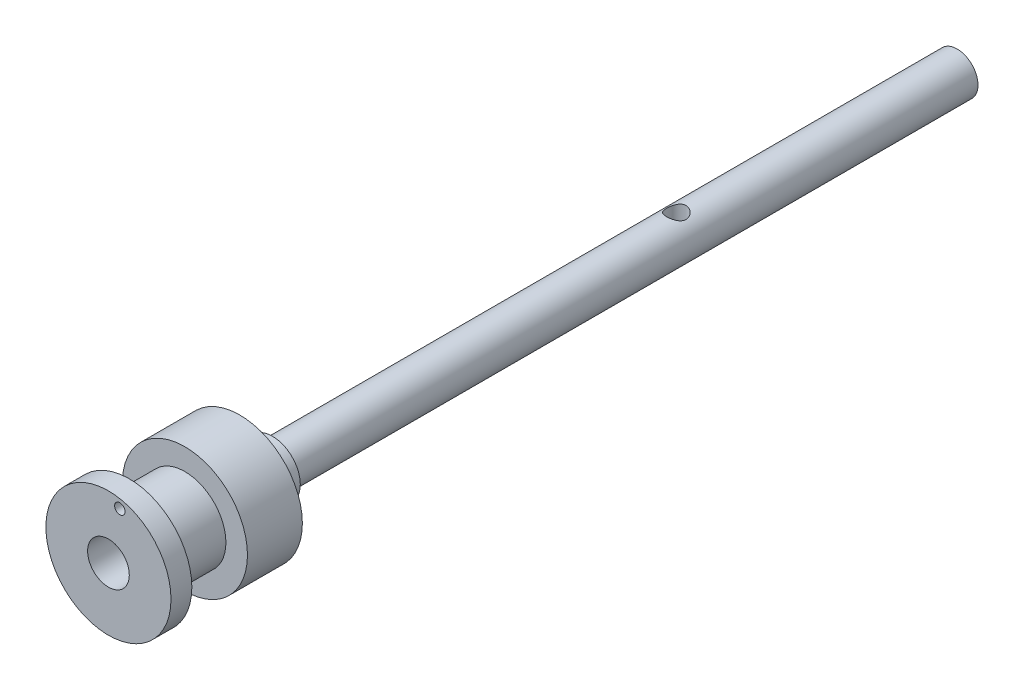
from build123d import *

# Parameters (mm, degrees)
SKETCH1_R               = 3
BOSS_EXTRUDE1_DEPTH     = 98.5
SKETCH2_R               = 4
BOSS_EXTRUDE2_DEPTH     = 4.7
SKETCH3_R               = 9
BOSS_EXTRUDE3_DEPTH     = 7.9
SKETCH4_R               = 5.9
BOSS_EXTRUDE4_DEPTH     = 8
SKETCH5_R               = 9
BOSS_EXTRUDE5_DEPTH     = 3
CUT_EXTRUDE1_DEPTH      = 82
CUT_EXTRUDE1_DEPTH_BACK = 82
SKETCH6_R               = 1.4
CUT_EXTRUDE2_START      = -9
SKETCH7_R               = 3
SKETCH7_R_2             = 0.75
CUT_EXTRUDE2_DEPTH      = 9


with BuildPart() as part:
    # Sketch1 → Boss-Extrude1 (new body)
    with BuildSketch(Plane.XY):
        Circle(SKETCH1_R)
    extrude(amount=BOSS_EXTRUDE1_DEPTH)

    # Sketch2 → Boss-Extrude2 (add)
    with BuildSketch(Plane.XY.offset(98.5)):
        Circle(SKETCH2_R)
    extrude(amount=BOSS_EXTRUDE2_DEPTH)

    # Sketch3 → Boss-Extrude3 (add)
    with BuildSketch(Plane.XY.offset(103.2)):
        Circle(SKETCH3_R)
    extrude(amount=BOSS_EXTRUDE3_DEPTH)

    # Sketch4 → Boss-Extrude4 (add)
    with BuildSketch(Plane.XY.offset(111.1)):
        Circle(SKETCH4_R)
    extrude(amount=BOSS_EXTRUDE4_DEPTH)

    # Sketch5 → Boss-Extrude5 (add)
    with BuildSketch(Plane.XY.offset(119.1)):
        Circle(SKETCH5_R)
    extrude(amount=BOSS_EXTRUDE5_DEPTH)

    # Sketch6 → Cut-Extrude1 (cut, two sides: drawn at the far end of the back side and taken through both)
    with BuildSketch(Plane(origin=(0, 0, 0), x_dir=(1, 0, 0), z_dir=(0, 1, 0)).offset(-CUT_EXTRUDE1_DEPTH_BACK)):
        with Locations((0, -40.4)):
            Circle(SKETCH6_R)
    extrude(amount=CUT_EXTRUDE1_DEPTH + CUT_EXTRUDE1_DEPTH_BACK, mode=Mode.SUBTRACT)

    # Sketch7 → Cut-Extrude2 (cut)
    with BuildSketch(Plane.XY.offset(122.1).offset(CUT_EXTRUDE2_START)):
        Circle(SKETCH7_R)
        with Locations((1.637751338, 7.588247864)):
            Circle(SKETCH7_R_2)
    extrude(amount=CUT_EXTRUDE2_DEPTH, mode=Mode.SUBTRACT)


solid = part.part
